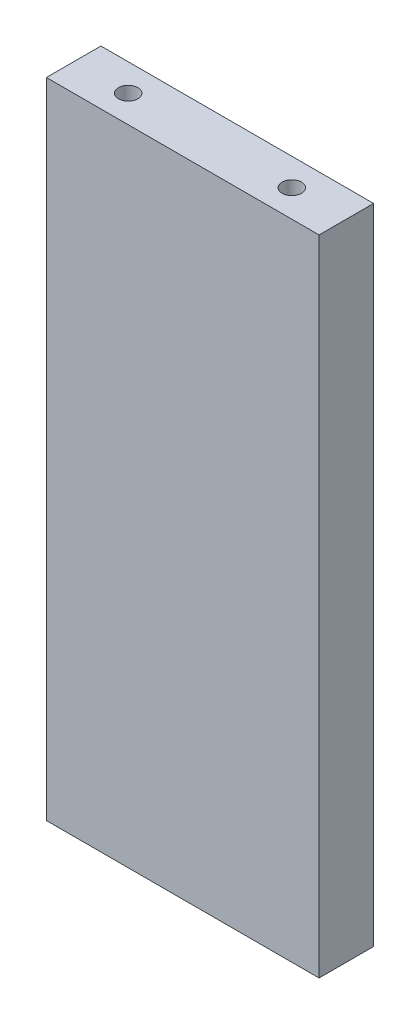
from build123d import *

# Parameters (mm, degrees)
SKETCH1_W                 = 31.75
SKETCH1_H                 = 6.35
BOSS_EXTRUDE1_DEPTH       = 74.93
F_4_40_TAPPED_HOLE1_D     = 2.2606
F_4_40_TAPPED_HOLE1_DEPTH = 7.5946
F_4_40_TAPPED_HOLE1_TIP   = 0.679152758
F_4_40_TAPPED_HOLE2_D     = 2.2606
F_4_40_TAPPED_HOLE2_DEPTH = 7.5946
F_4_40_TAPPED_HOLE2_TIP   = 0.679152758


with BuildPart() as part:
    # Sketch1 → Boss-Extrude1 (new body)
    with BuildSketch(Plane(origin=(0, 0, 0), x_dir=(1, 0, 0), z_dir=(0, 1, 0))):
        Rectangle(SKETCH1_W, SKETCH1_H)
    extrude(amount=BOSS_EXTRUDE1_DEPTH)

    # #4-40 Tapped Hole1
    with Locations(Plane(origin=(0, 0, 0), x_dir=(-1, 0, 0), z_dir=(0, -1, 0))):
        with Locations((9.525, 0), (-9.525, 0)):
            Hole(F_4_40_TAPPED_HOLE1_D / 2, depth=F_4_40_TAPPED_HOLE1_DEPTH)
            with Locations((0, 0, -(F_4_40_TAPPED_HOLE1_DEPTH + F_4_40_TAPPED_HOLE1_TIP / 2))):  # 118° drill point
                Cone(0, F_4_40_TAPPED_HOLE1_D / 2, F_4_40_TAPPED_HOLE1_TIP, mode=Mode.SUBTRACT)

    # #4-40 Tapped Hole2
    with Locations(Plane(origin=(0, 74.93, 0), x_dir=(1, 0, 0), z_dir=(0, 1, 0))):
        with Locations((-9.525, 0), (9.525, 0)):
            Hole(F_4_40_TAPPED_HOLE2_D / 2, depth=F_4_40_TAPPED_HOLE2_DEPTH)
            with Locations((0, 0, -(F_4_40_TAPPED_HOLE2_DEPTH + F_4_40_TAPPED_HOLE2_TIP / 2))):  # 118° drill point
                Cone(0, F_4_40_TAPPED_HOLE2_D / 2, F_4_40_TAPPED_HOLE2_TIP, mode=Mode.SUBTRACT)


solid = part.part
